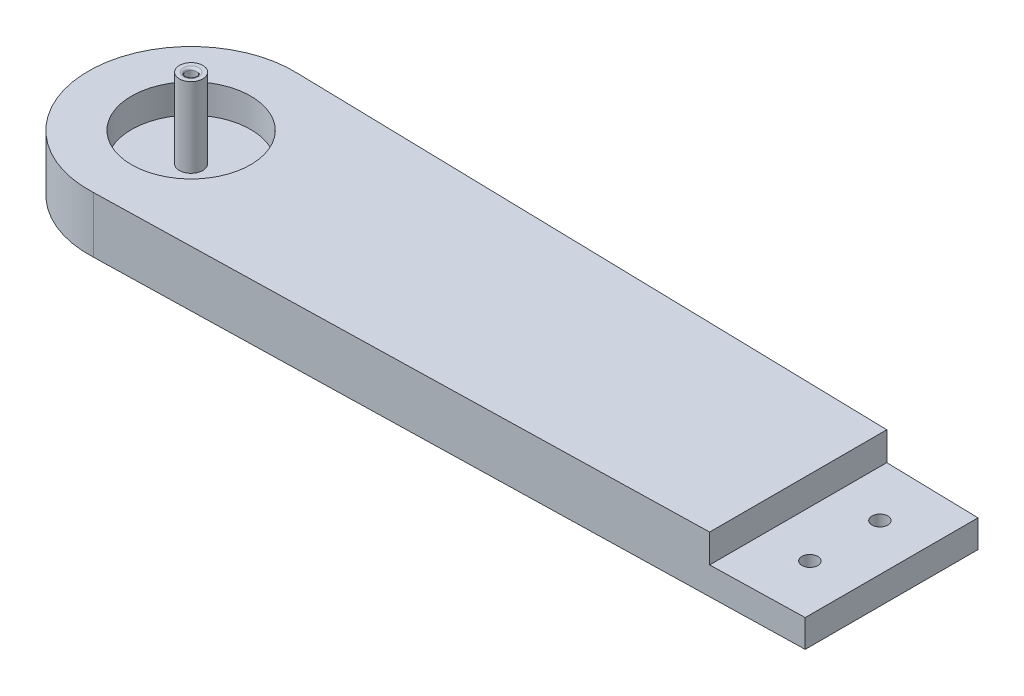
from build123d import *

# Parameters (mm, degrees)
SKETCH1_R           = 22
BOSS_EXTRUDE1_DEPTH = 12
SKETCH2_R           = 12.75
CUT_EXTRUDE1_DEPTH  = 6.2
SKETCH5_R           = 2.5
BOSS_EXTRUDE2_DEPTH = 17
SKETCH6_R           = 1.15
CUT_EXTRUDE2_DEPTH  = 34.1
SKETCH7_R           = 2
CUT_EXTRUDE3_DEPTH  = 20
FILLET1_R           = 1
FILLET2_R           = 0.5
BOSS_EXTRUDE4_DEPTH = 12
CUT_EXTRUDE5_DEPTH  = 6.1
SKETCH10_R          = 1.7
CUT_EXTRUDE6_DEPTH  = 6.1
SKETCH11_R          = 2.8
CUT_EXTRUDE7_DEPTH  = 3
FILLET3_R           = 0.5


with BuildPart() as part:
    # Sketch1 → Boss-Extrude1 (new body)
    with BuildSketch(Plane(origin=(0, 0, 0), x_dir=(1, 0, 0), z_dir=(0, 1, 0))):
        Circle(SKETCH1_R)
    extrude(amount=BOSS_EXTRUDE1_DEPTH)

    # Sketch2 → Cut-Extrude1 (cut)
    with BuildSketch(Plane(origin=(0, 12, 0), x_dir=(1, 0, 0), z_dir=(0, 1, 0))):
        Circle(SKETCH2_R)
    extrude(amount=-CUT_EXTRUDE1_DEPTH, mode=Mode.SUBTRACT)

    # Sketch5 → Boss-Extrude2 (add)
    with BuildSketch(Plane(origin=(0, 5.8, 0), x_dir=(1, 0, 0), z_dir=(0, 1, 0))):
        Circle(SKETCH5_R)
    extrude(amount=BOSS_EXTRUDE2_DEPTH)

    # Sketch6 → Cut-Extrude2 (cut)
    with BuildSketch(Plane.XZ):
        Circle(SKETCH6_R)
    extrude(amount=-CUT_EXTRUDE2_DEPTH, mode=Mode.SUBTRACT)

    # Sketch7 → Cut-Extrude3 (cut)
    with BuildSketch(Plane.XZ):
        Circle(SKETCH7_R)
    extrude(amount=-CUT_EXTRUDE3_DEPTH, mode=Mode.SUBTRACT)

    # Fillet1
    fillet1_edges = [part.edges().sort_by_distance(p)[0] for p in [
        (-2, 0, 0),
    ]]
    fillet(fillet1_edges, radius=FILLET1_R)

    # Fillet2
    fillet2_edges = [part.edges().sort_by_distance(p)[0] for p in [
        (-1.15, 22.8, 0),
    ]]
    fillet(fillet2_edges, radius=FILLET2_R)

    # Sketch8 → Boss-Extrude4 (add)
    with BuildSketch(Plane.XZ):
        with BuildLine():
            Line((1.026108008, -21.97605748), (150, -18.5))
            Line((150, -18.5), (150, 18.5))
            Line((150, 18.5), (1.026108008, 21.97605748))
            ThreePointArc((1.026108008, 21.97605748), (22, 0), (1.026108008, -21.97605748))
        make_face()
    extrude(amount=-BOSS_EXTRUDE4_DEPTH)

    # Sketch9 → Cut-Extrude5 (cut)
    with BuildSketch(Plane(origin=(0, 12, 0), x_dir=(1, 0, 0), z_dir=(0, 1, 0))):
        Polygon((150, 18.5), (130, 18.966666667), (130, -18.966666667), (150, -18.5), align=None)
    extrude(amount=-CUT_EXTRUDE5_DEPTH, mode=Mode.SUBTRACT)

    # Sketch10 → Cut-Extrude6 (cut)
    with BuildSketch(Plane.XZ):
        with Locations((140, -7.5)):
            Circle(SKETCH10_R)
        with Locations((140, 7.5)):
            Circle(SKETCH10_R)
    extrude(amount=-CUT_EXTRUDE6_DEPTH, mode=Mode.SUBTRACT)

    # Sketch11 → Cut-Extrude7 (cut)
    with BuildSketch(Plane.XZ):
        with Locations((140, 7.5)):
            Circle(SKETCH11_R)
        with Locations((140, -7.5)):
            Circle(SKETCH11_R)
    extrude(amount=-CUT_EXTRUDE7_DEPTH, mode=Mode.SUBTRACT)

    # Fillet3
    fillet3_edges = [part.edges().sort_by_distance(p)[0] for p in [
        (137.2, 0, 7.5),
        (137.2, 0, -7.5),
    ]]
    fillet(fillet3_edges, radius=FILLET3_R)


solid = part.part
